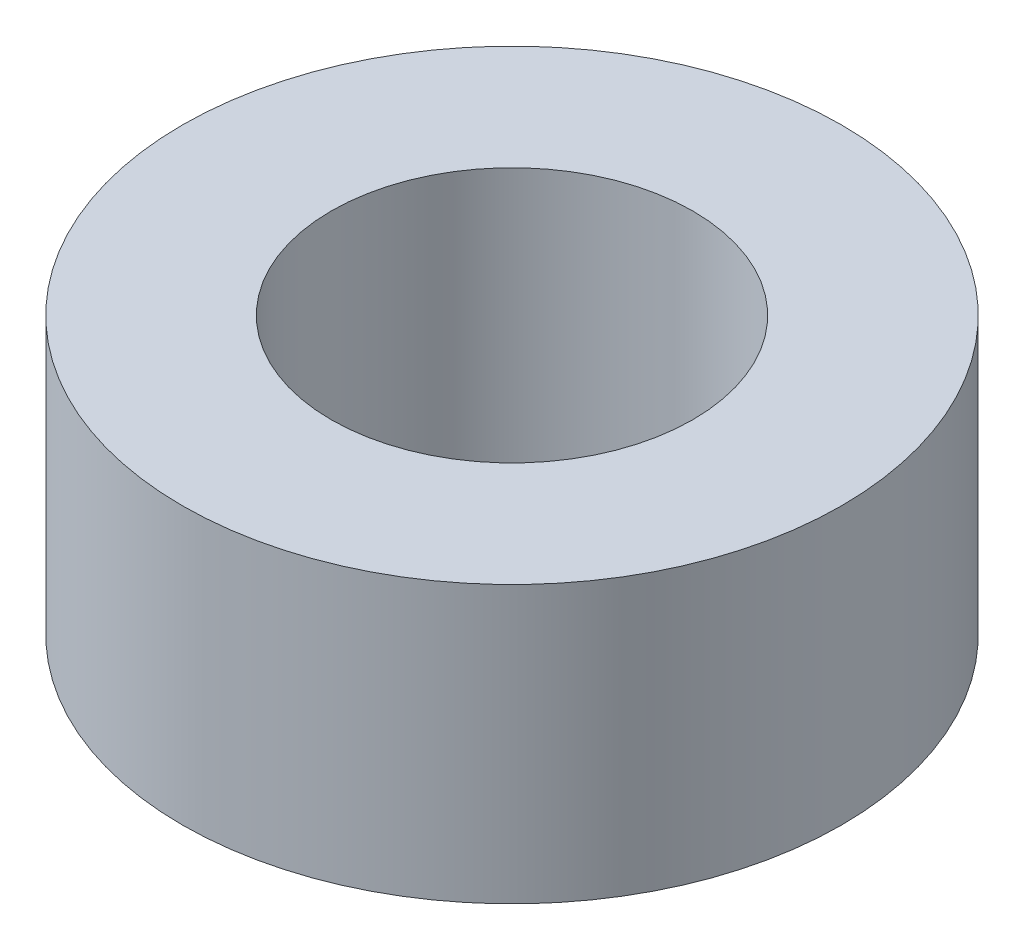
from build123d import *

# Parameters (mm, degrees)
SKETCH1_R           = 3.1
SKETCH1_R_2         = 1.7
BOSS_EXTRUDE1_DEPTH = 1.3


with BuildPart() as part:
    # Sketch1 → Boss-Extrude1 (new body, symmetric)
    with BuildSketch(Plane(origin=(0, 0, 0), x_dir=(1, 0, 0), z_dir=(0, 1, 0))):
        Circle(SKETCH1_R)
        Circle(SKETCH1_R_2, mode=Mode.SUBTRACT)
    extrude(amount=BOSS_EXTRUDE1_DEPTH, both=True)


solid = part.part
